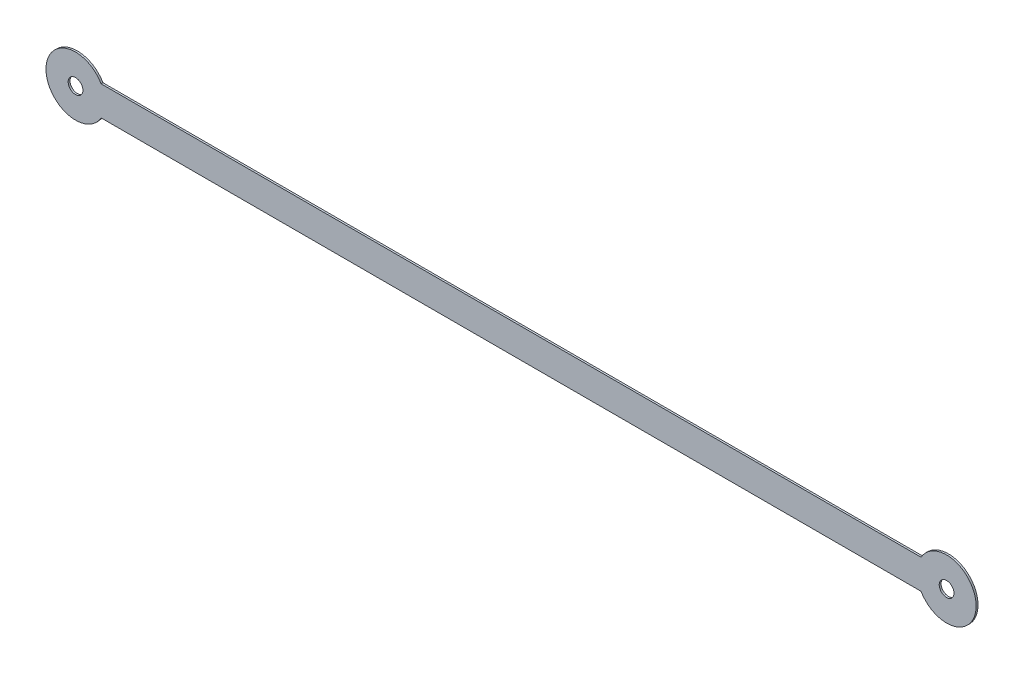
from build123d import *

# Parameters (mm, degrees)
SKETCH1_R           = 1
BOSS_EXTRUDE1_DEPTH = 0.254
CUT_EXTRUDE1_DEPTH  = 1.254


with BuildPart() as part:
    # Sketch1 → Boss-Extrude1 (new body)
    with BuildSketch(Plane.XY):
        with BuildLine():
            Line((0, 4), (118, 4))
            ThreePointArc((118, 4), (122, 0), (118, -4))
            Line((118, -4), (0, -4))
            ThreePointArc((0, -4), (-4, 0), (0, 4))
        make_face()
        Circle(SKETCH1_R, mode=Mode.SUBTRACT)
        with Locations((118, 0)):
            Circle(SKETCH1_R, mode=Mode.SUBTRACT)
    extrude(amount=BOSS_EXTRUDE1_DEPTH)

    # Sketch2 → Cut-Extrude1 (cut, through all)
    with BuildSketch(Plane(origin=(0, 0, 0), x_dir=(-1, 0, 0), z_dir=(0, 0, -1))):
        with BuildLine():
            Line((-114.535898385, 2), (-3.464101615, 2))
            ThreePointArc((-3.464101615, 2), (-2, 3.464101615), (0, 4))
            Line((0, 4), (-118, 4))
            ThreePointArc((-118, 4), (-116, 3.464101615), (-114.535898385, 2))
        make_face()
        with BuildLine():
            Line((-114.535898385, -2), (-3.464101615, -2))
            ThreePointArc((-3.464101615, -2), (-2, -3.464101615), (0, -4))
            Line((0, -4), (-118, -4))
            ThreePointArc((-118, -4), (-116, -3.464101615), (-114.535898385, -2))
        make_face()
    extrude(amount=-CUT_EXTRUDE1_DEPTH, mode=Mode.SUBTRACT)


solid = part.part
